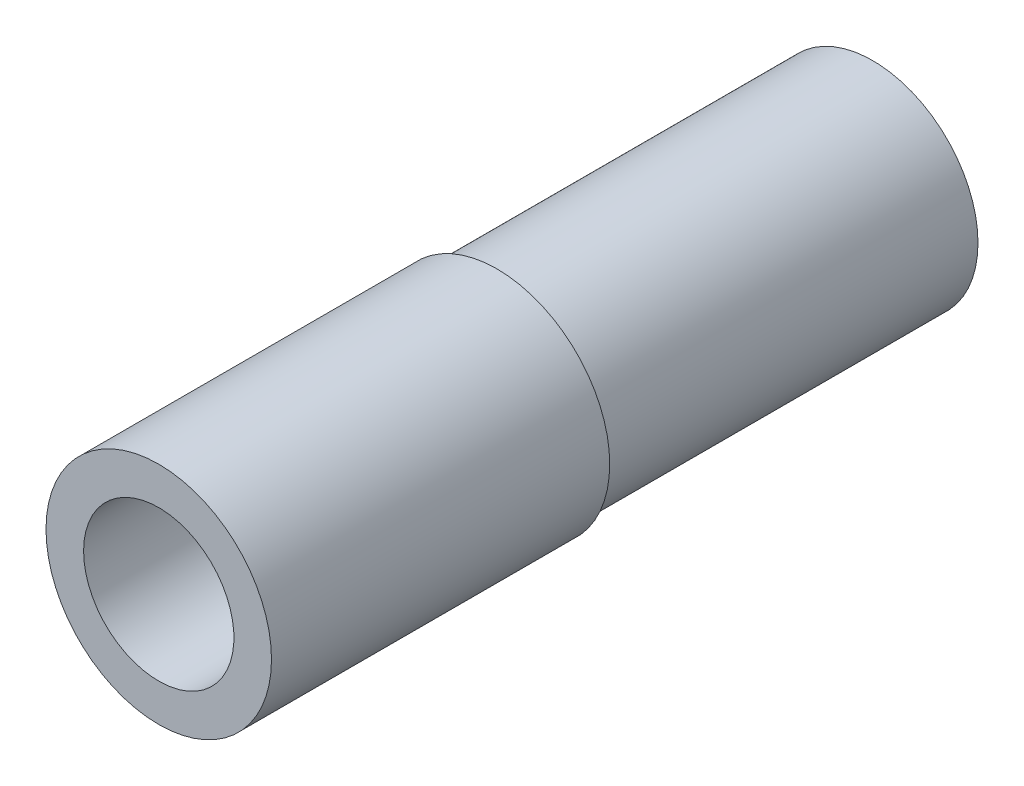
from build123d import *

# Parameters (mm, degrees)
SKETCH1_R           = 15
BOSS_EXTRUDE1_DEPTH = 45
SKETCH2_R           = 10
CUT_EXTRUDE1_DEPTH  = 46
SKETCH3_R           = 14
BOSS_EXTRUDE2_DEPTH = 50
SKETCH5_R           = 10
CUT_EXTRUDE2_DEPTH  = 18


with BuildPart() as part:
    # Sketch1 → Boss-Extrude1 (new body)
    with BuildSketch(Plane.XY):
        Circle(SKETCH1_R)
    extrude(amount=BOSS_EXTRUDE1_DEPTH)

    # Sketch2 → Cut-Extrude1 (cut, through all)
    with BuildSketch(Plane(origin=(0, 0, 0), x_dir=(-1, 0, 0), z_dir=(0, 0, -1))):
        Circle(SKETCH2_R)
    extrude(amount=-CUT_EXTRUDE1_DEPTH, mode=Mode.SUBTRACT)

    # Sketch3 → Boss-Extrude2 (add)
    with BuildSketch(Plane(origin=(0, 0, 0), x_dir=(-1, 0, 0), z_dir=(0, 0, -1))):
        Circle(SKETCH3_R)
    extrude(amount=BOSS_EXTRUDE2_DEPTH)

    # Sketch5 → Cut-Extrude2 (cut)
    with BuildSketch(Plane(origin=(0, 0, -50), x_dir=(-1, 0, 0), z_dir=(0, 0, -1))):
        Circle(SKETCH5_R)
    extrude(amount=-CUT_EXTRUDE2_DEPTH, mode=Mode.SUBTRACT)


solid = part.part
